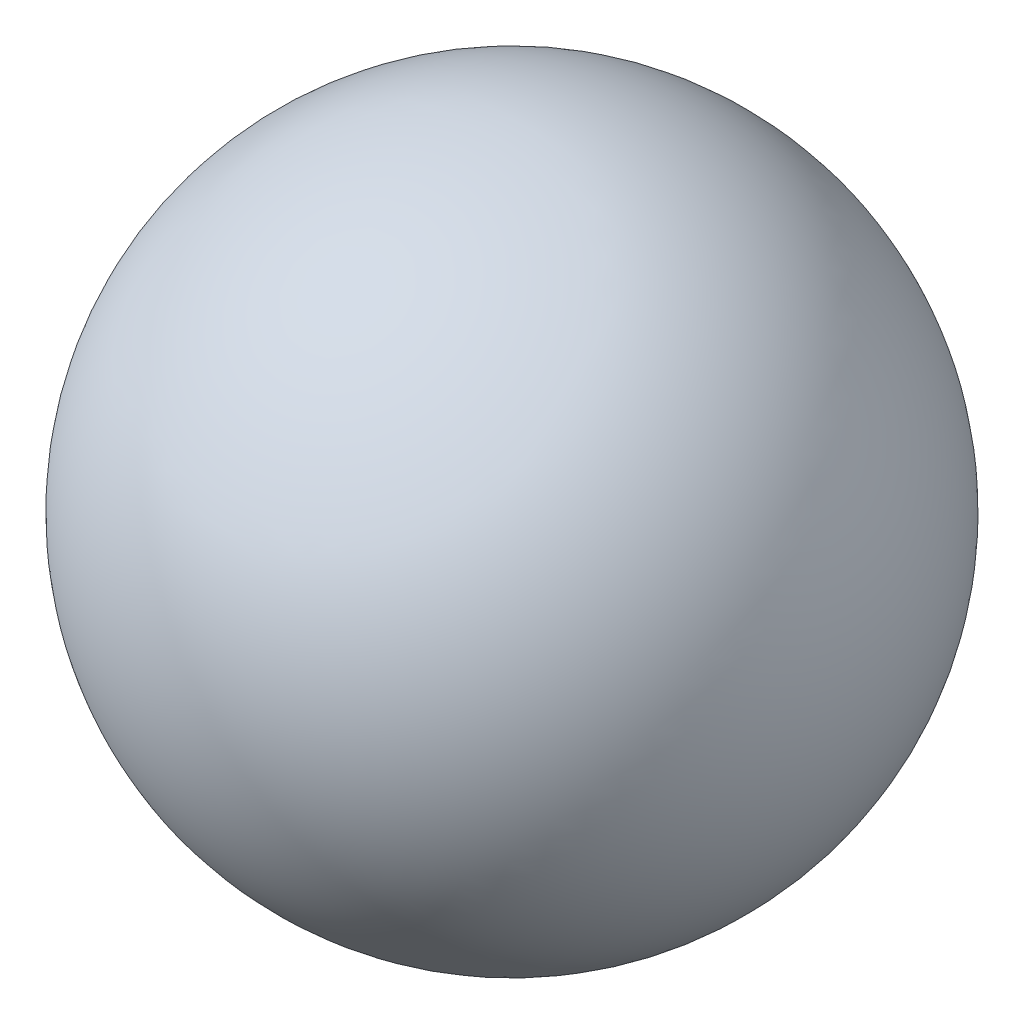
from build123d import *


with BuildPart() as part:
    # Sketch2 → Revolve1 (revolve)
    with BuildSketch(Plane(origin=(0, 0, 0), x_dir=(1, 0, 0), z_dir=(0, 1, 0))):
        with BuildLine():
            Line((0, 38.1), (0, -38.1))
            ThreePointArc((0, -38.1), (38.1, 0), (0, 38.1))
        make_face()
    revolve(axis=Axis((0, 0, -38.1), (0, 0, 1)))


solid = part.part
